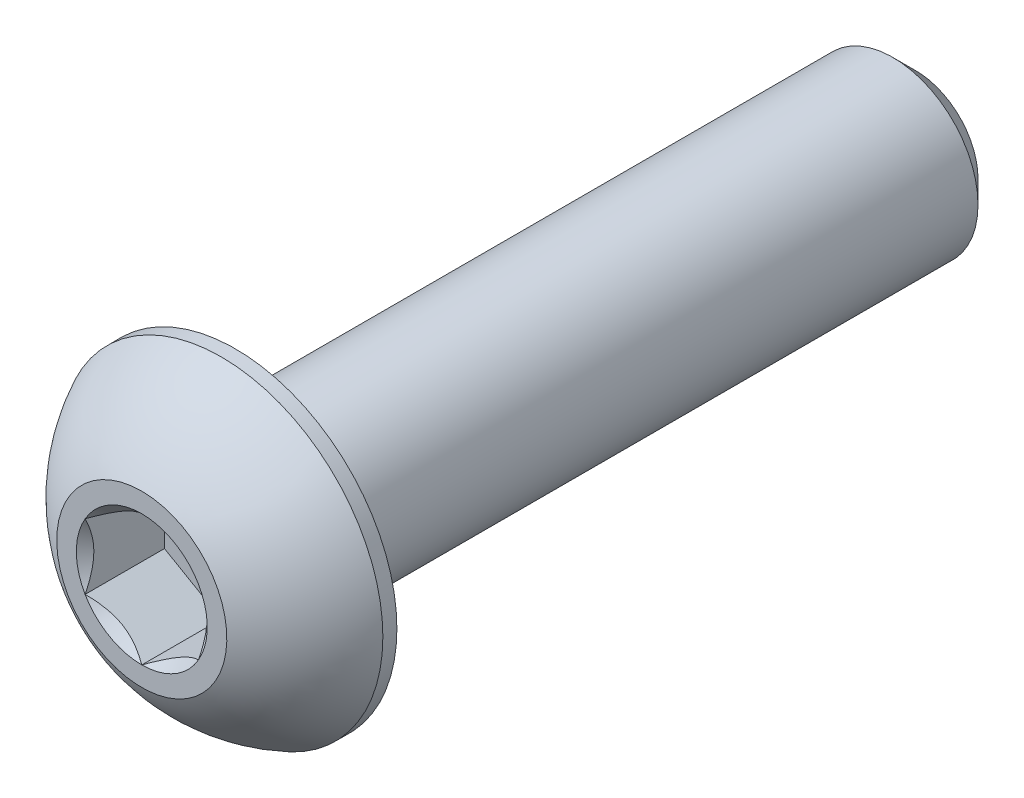
from build123d import *

# Parameters (mm, degrees)
CUT_EXTRUDE1_DEPTH = 1.4


with BuildPart() as part:
    # Sketch2 → Revolve1 (revolve)
    with BuildSketch(Plane(origin=(0, 0, 0), x_dir=(0, 0, -1), z_dir=(1, 0, 0)), mode=Mode.PRIVATE) as revolve1_sk:
        with BuildLine():
            Line((-6.825, 0), (6.825, 0))
            Line((6.825, 0), (6.825, 1.1))
            Line((6.825, 1.1), (6.425, 1.5))
            Line((6.425, 1.5), (-5.175, 1.5))
            Line((-5.175, 1.5), (-5.175, 2.85))
            Line((-5.175, 2.85), (-5.4225, 2.85))
            ThreePointArc((-5.4225, 2.85), (-6.22987489, 2.285251969), (-6.825, 1.5))
            Line((-6.825, 1.5), (-6.825, 0))
        make_face()
    revolve(revolve1_sk.sketch.rotate(Axis((0, 0, 6.825), (0, 0, -1)), 90), axis=Axis((0, 0, 6.825), (0, 0, -1)))

    # Sketch3 → Cut-Extrude1 (cut)
    with BuildSketch(Plane.XY.offset(6.825)):
        Polygon((0, 1.154700538), (-1, 0.577350269), (-1, -0.577350269), (0, -1.154700538), (1, -0.577350269), (1, 0.577350269), align=None)
    extrude(amount=-CUT_EXTRUDE1_DEPTH, mode=Mode.SUBTRACT)

    # Cut-Extrude2 cone 1 section (through the dimple's axis) → Cut-Extrude2 (revolve, cut)
    with BuildSketch(Plane(origin=(0, 0, 6.825), x_dir=(0, -1, 0), z_dir=(1, 0, 0))):
        Polygon((0, 0), (1.154700538, 0), (0, 1.154700538), align=None)
    revolve(axis=Axis((0, 0, 6.825), (0, 0, -1)), mode=Mode.SUBTRACT)


solid = part.part
